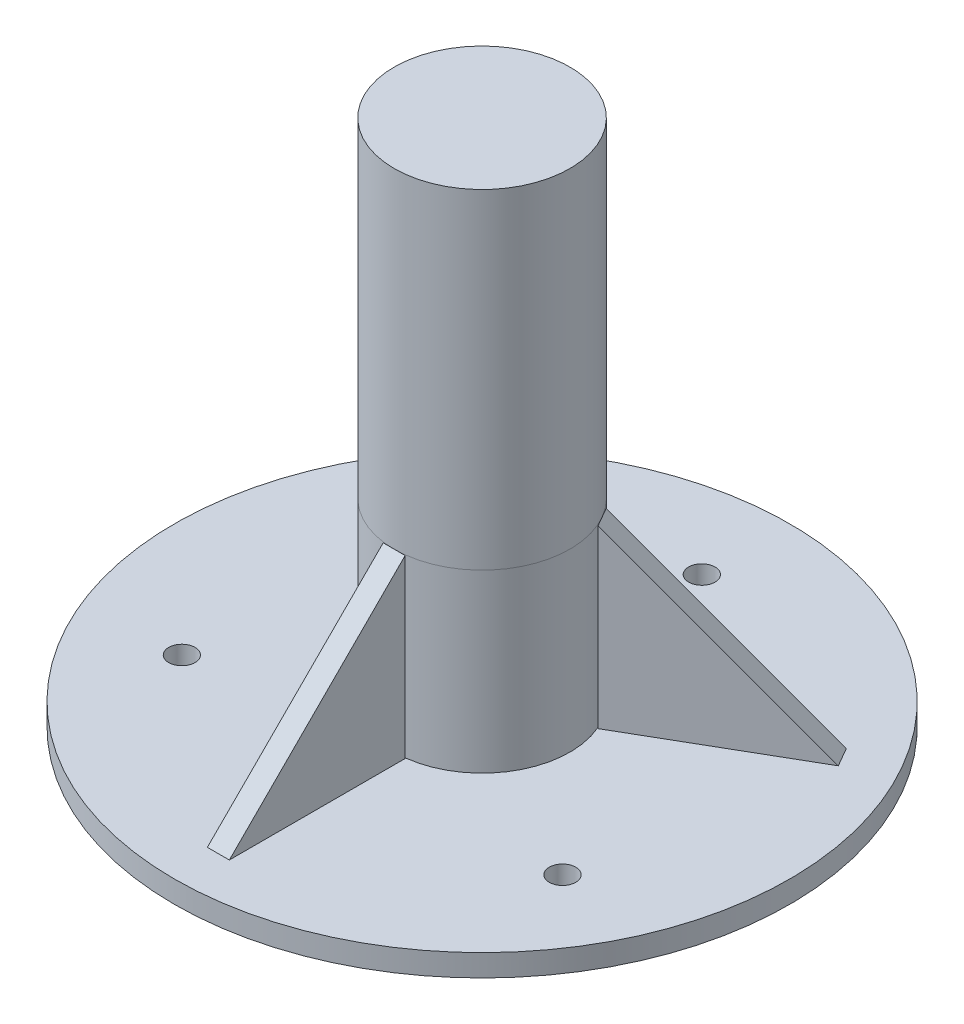
from build123d import *

# Parameters (mm, degrees)
SKETCH1_R           = 70
BOSS_EXTRUDE1_DEPTH = 5
SKETCH2_R           = 20
BOSS_EXTRUDE2_DEPTH = 40
SKETCH3_R           = 20
BOSS_EXTRUDE3_DEPTH = 75
BOSS_EXTRUDE4_DEPTH = 2.5
CIRPATTERN1_COUNT   = 3
SKETCH5_R           = 3
CUT_EXTRUDE1_DEPTH  = 152.739909055


with BuildPart() as part:
    # Sketch1 → Boss-Extrude1 (new body)
    with BuildSketch(Plane(origin=(0, 0, 0), x_dir=(1, 0, 0), z_dir=(0, 1, 0))):
        Circle(SKETCH1_R)
    extrude(amount=-BOSS_EXTRUDE1_DEPTH)


with BuildPart() as body_2:
    # Sketch2 → Boss-Extrude2 (new body)
    with BuildSketch(Plane(origin=(0, 0, 0), x_dir=(1, 0, 0), z_dir=(0, 1, 0))):
        Circle(SKETCH2_R)
    extrude(amount=BOSS_EXTRUDE2_DEPTH)


with BuildPart() as body_3:
    # Sketch3 → Boss-Extrude3 (new body)
    with BuildSketch(Plane(origin=(0, 40, 0), x_dir=(1, 0, 0), z_dir=(0, 1, 0))):
        Circle(SKETCH3_R)
    extrude(amount=BOSS_EXTRUDE3_DEPTH)


with BuildPart() as body_4:
    # Sketch4 → Boss-Extrude4 (new, symmetric)
    with BuildSketch(Plane(origin=(0, 0, 0), x_dir=(0, 0, -1), z_dir=(1, 0, 0))):
        Polygon((-60, 0), (-20, 0), (-20, 40), align=None)
    boss_extrude4 = extrude(amount=BOSS_EXTRUDE4_DEPTH, both=True)


with BuildPart() as part_1:
    add(part.part)

    # CirPattern1: Boss-Extrude4 ×3 about axis
    cirpattern1_axis = Axis((0, 40, 0), (0, -1, 0))
    for i in range(1, CIRPATTERN1_COUNT):
        add(boss_extrude4.rotate(cirpattern1_axis, i * 360 / CIRPATTERN1_COUNT))

    # Sketch5 → Cut-Extrude1 (cut, through all)
    with BuildSketch(Plane(origin=(0, 0, 0), x_dir=(1, 0, 0), z_dir=(0, 1, 0))):
        with Locations((-43.301270189, -25)):
            Circle(SKETCH5_R)
        with Locations((0, 50)):
            Circle(SKETCH5_R)
        with Locations((43.301270189, -25)):
            Circle(SKETCH5_R)
    extrude(amount=-CUT_EXTRUDE1_DEPTH, mode=Mode.SUBTRACT)


solid = Compound([body_2.part, body_3.part, body_4.part, part_1.part])
